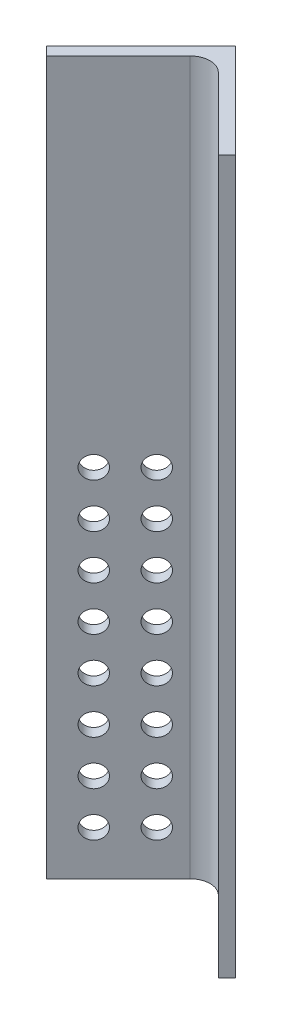
from build123d import *

# Parameters (mm, degrees)
BOSS_EXTRUDE1_DEPTH             = 101.6
FILLET1_R                       = 5.715
F_1_4_0_25_DIAMETER_HOLE1_D     = 6.35
F_1_4_0_25_DIAMETER_HOLE1_DEPTH = 3.4544
LPATTERN1_COUNT                 = 2
LPATTERN1_PITCH                 = 12.7
LPATTERN1_COUNT_DIR2            = 8
LPATTERN1_PITCH_DIR2            = 12.7


with BuildPart() as part:
    # Sketch1 → Boss-Extrude1 (new body, symmetric)
    with BuildSketch(Plane(origin=(0, 0, 0), x_dir=(1, 0, 0), z_dir=(0, 1, 0))):
        Polygon((0, 0), (-26.940768363, -26.940768363), (-24.498138698, -29.383398028), (0, -4.88525933), (24.498138698, -29.383398028), (26.940768363, -26.940768363), align=None)
    extrude(amount=BOSS_EXTRUDE1_DEPTH, both=True)

    # Fillet1
    fillet1_edges = [part.edges().sort_by_distance(p)[0] for p in [
        (0, 0, 4.88525933),
    ]]
    fillet(fillet1_edges, radius=FILLET1_R)

    # 1/4 (0.25) Diameter Hole1
    with Locations(Plane(origin=(2.442629665, 0, 2.442629665), x_dir=(0.707106781, 0, -0.707106781), z_dir=(0.707106781, 0, 0.707106781))):
        with Locations((-28.575, 0)):
            f_1_4_0_25_diameter_hole1 = Hole(F_1_4_0_25_DIAMETER_HOLE1_D / 2, depth=F_1_4_0_25_DIAMETER_HOLE1_DEPTH)

    # LPattern1: 1_4 _0.25_ Diameter Hole1 2 × 8
    with Locations(*[Vector(0.707106781, 0, -0.707106781) * (i * LPATTERN1_PITCH) + Vector(0, -1, 0) * (j * LPATTERN1_PITCH_DIR2) for i in range(LPATTERN1_COUNT) for j in range(LPATTERN1_COUNT_DIR2) if (i, j) != (0, 0)]):
        add(f_1_4_0_25_diameter_hole1, mode=Mode.SUBTRACT)


solid = part.part
